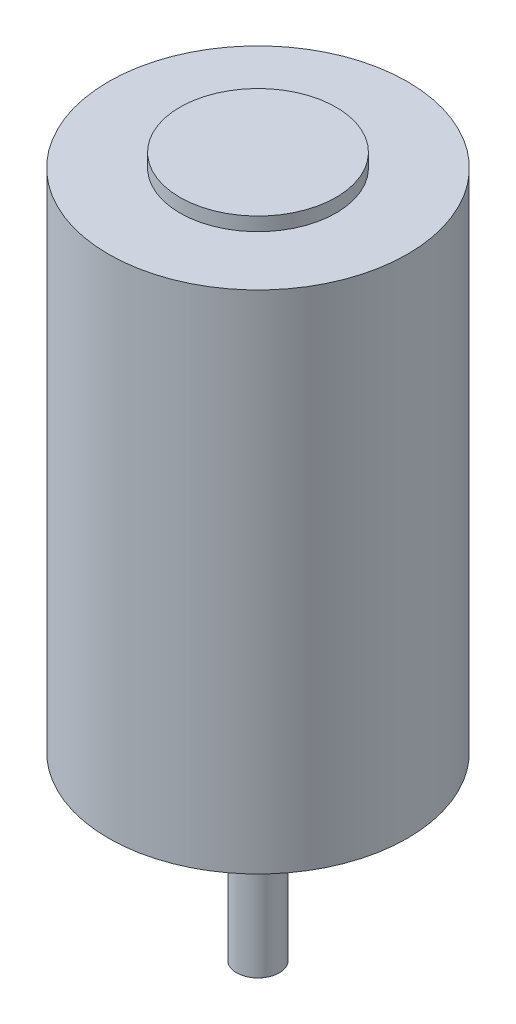
from build123d import *

# Parameters (mm, degrees)
SKETCH2_R           = 21.0185
BOSS_EXTRUDE1_DEPTH = 71.12
SKETCH3_R           = 10.9855
BOSS_EXTRUDE2_DEPTH = 1.905
SKETCH4_R           = 10.9855
SKETCH4_R_2         = 8.4455
BOSS_EXTRUDE3_DEPTH = 1.905
SKETCH5_R           = 3
BOSS_EXTRUDE4_DEPTH = 25.4
SKETCH6_R           = 5.08
BOSS_EXTRUDE5_DEPTH = 3.429
SKETCH7_R           = 1.27
CUT_EXTRUDE1_DEPTH  = 5.08


with BuildPart() as part:
    # Sketch2 → Boss-Extrude1 (new body)
    with BuildSketch(Plane(origin=(0, 0, 0), x_dir=(1, 0, 0), z_dir=(0, 1, 0))):
        Circle(SKETCH2_R)
    extrude(amount=BOSS_EXTRUDE1_DEPTH)

    # Sketch3 → Boss-Extrude2 (add)
    with BuildSketch(Plane(origin=(0, 71.12, 0), x_dir=(1, 0, 0), z_dir=(0, 1, 0))):
        Circle(SKETCH3_R)
    extrude(amount=BOSS_EXTRUDE2_DEPTH)

    # Sketch4 → Boss-Extrude3 (add)
    with BuildSketch(Plane.XZ):
        Circle(SKETCH4_R)
        Circle(SKETCH4_R_2, mode=Mode.SUBTRACT)
    extrude(amount=BOSS_EXTRUDE3_DEPTH)

    # Sketch5 → Boss-Extrude4 (add)
    with BuildSketch(Plane.XZ):
        Circle(SKETCH5_R)
    extrude(amount=BOSS_EXTRUDE4_DEPTH)

    # Sketch6 → Boss-Extrude5 (add)
    with BuildSketch(Plane.XZ):
        Circle(SKETCH6_R)
    extrude(amount=BOSS_EXTRUDE5_DEPTH)

    # Sketch7 → Cut-Extrude1 (cut)
    with BuildSketch(Plane.XZ):
        with Locations((16, 0)):
            Circle(SKETCH7_R)
        with Locations((-16, 0)):
            Circle(SKETCH7_R)
    extrude(amount=-CUT_EXTRUDE1_DEPTH, mode=Mode.SUBTRACT)


solid = part.part
